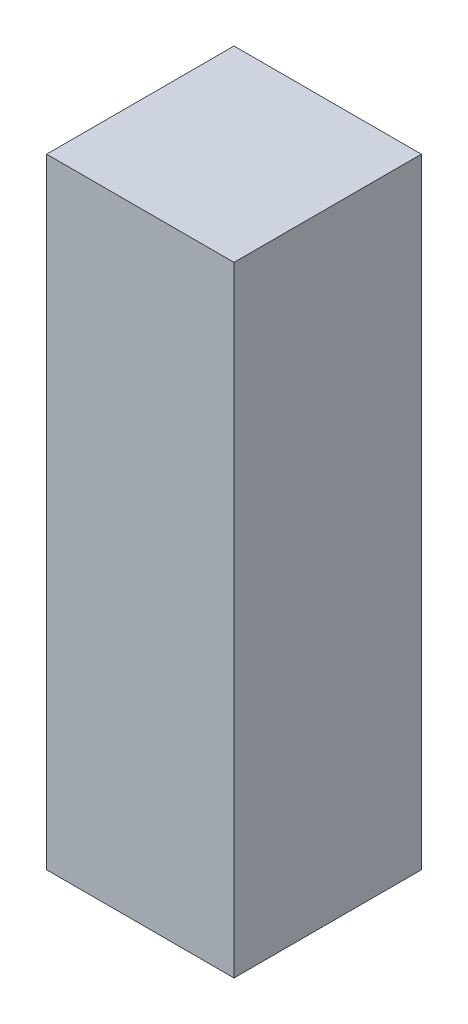
from build123d import *

# Parameters (mm, degrees)
ESQUISSE1_W        = 13
ESQUISSE1_H        = 43
BOSS_EXTRU_1_DEPTH = 13


with BuildPart() as part:
    # Esquisse1 → Boss.-Extru.1 (new body)
    with BuildSketch(Plane.XY):
        with Locations((-11.308650977, -13.62628866)):
            Rectangle(ESQUISSE1_W, ESQUISSE1_H)
    extrude(amount=BOSS_EXTRU_1_DEPTH)


solid = part.part
